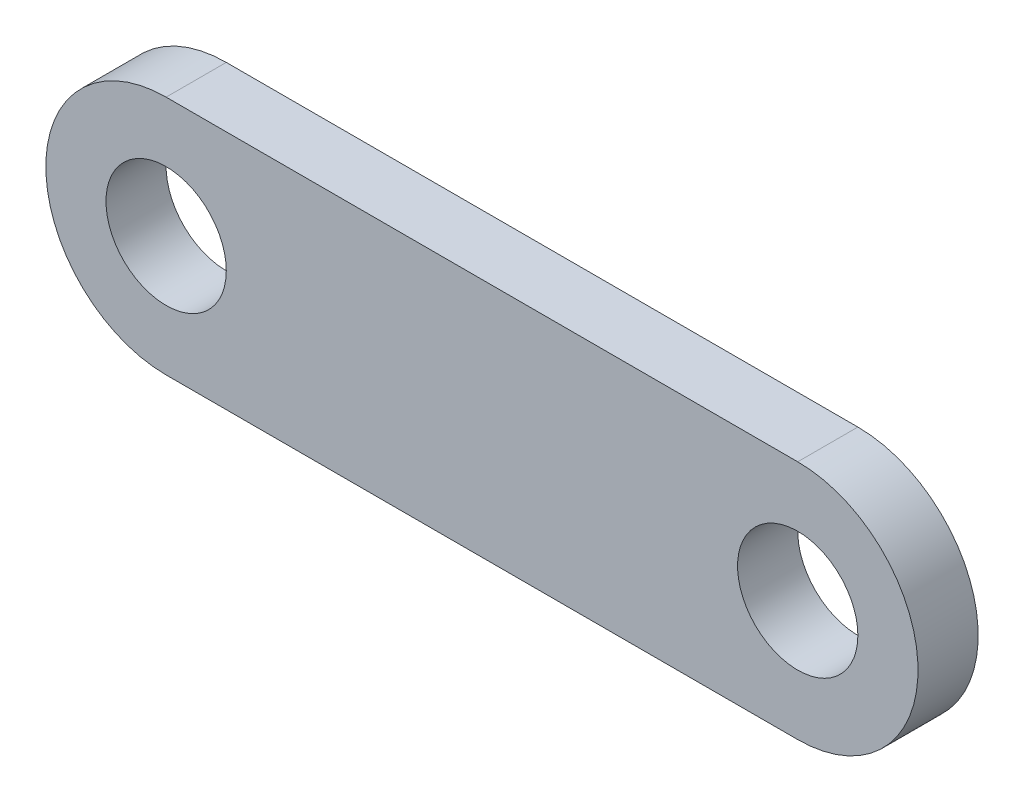
from build123d import *

# Parameters (mm, degrees)
SKETCH4_R           = 2.54
BOSS_EXTRUDE1_DEPTH = 2.54


with BuildPart() as part:
    # Sketch4 → Boss-Extrude1 (new body)
    with BuildSketch(Plane.XY):
        with BuildLine():
            Line((0, -5.08), (-26.67, -5.08))
            ThreePointArc((-26.67, -5.08), (-31.75, 0), (-26.67, 5.08))
            Line((-26.67, 5.08), (0, 5.08))
            ThreePointArc((0, 5.08), (5.08, 0), (0, -5.08))
        make_face()
        Circle(SKETCH4_R, mode=Mode.SUBTRACT)
        with Locations((-26.67, 0)):
            Circle(SKETCH4_R, mode=Mode.SUBTRACT)
    extrude(amount=BOSS_EXTRUDE1_DEPTH)


solid = part.part
